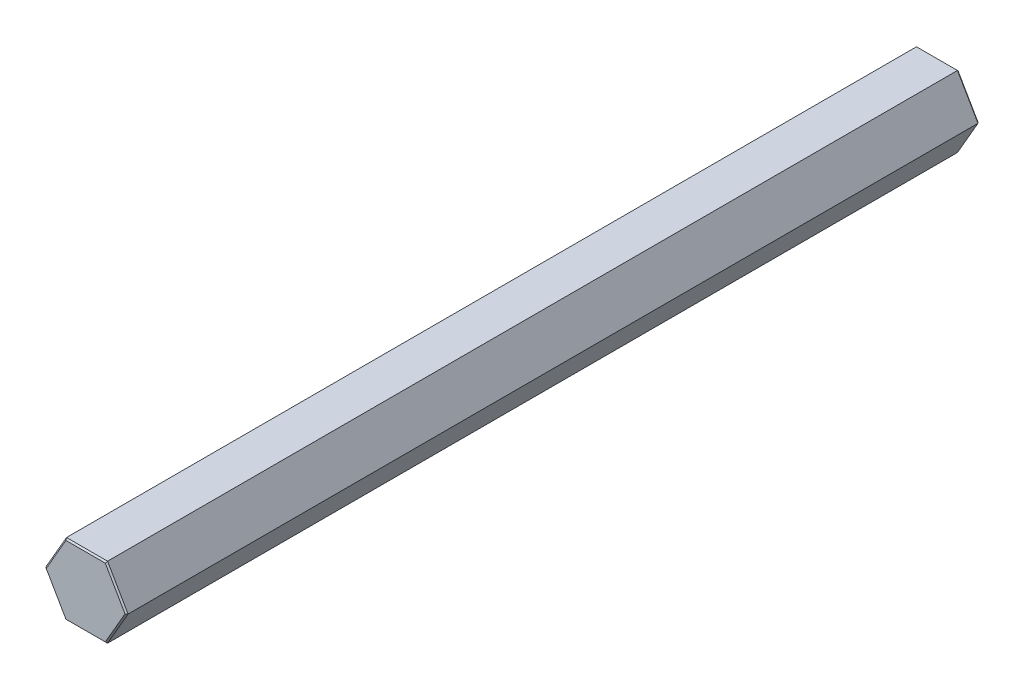
from build123d import *

# Parameters (mm, degrees)
BOSS_EXTRUDE1_DEPTH = 152.4
CHAMFER1_SIZE       = 0.254


with BuildPart() as part:
    # Sketch1 → Boss-Extrude1 (new body)
    with BuildSketch(Plane(origin=(0, 0, 0), x_dir=(-1, 0, 0), z_dir=(0, 0, -1))):
        Polygon((3.666174209, 6.35), (-3.666174209, 6.35), (-7.332348419, 0), (-3.666174209, -6.35), (3.666174209, -6.35), (7.332348419, 0), align=None)
    extrude(amount=-BOSS_EXTRUDE1_DEPTH)

    # Chamfer1
    chamfer1_edges = [part.edges().sort_by_distance(p)[0] for p in [
        (5.499261314, 3.175, 152.4),
        (5.499261314, -3.175, 152.4),
        (0, -6.35, 152.4),
        (-5.499261314, -3.175, 152.4),
        (-5.499261314, 3.175, 152.4),
        (-5.499261314, -3.175, 0),
        (0, -6.35, 0),
        (5.499261314, -3.175, 0),
        (5.499261314, 3.175, 0),
        (0, 6.35, 0),
        (-5.499261314, 3.175, 0),
        (0, 6.35, 152.4),
    ]]
    chamfer(chamfer1_edges, length=CHAMFER1_SIZE)


solid = part.part
